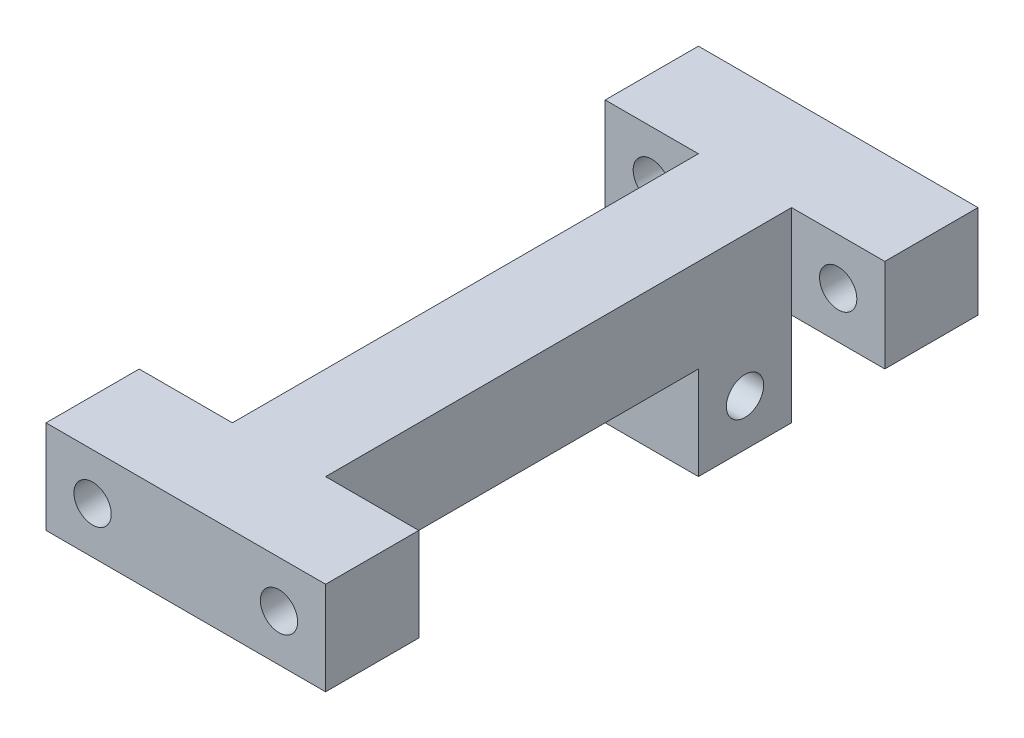
from build123d import *

# Parameters (mm, degrees)
SKETCH2_W           = 250
SKETCH2_H           = 100
BOSS_EXTRUDE1_DEPTH = 50
SKETCH3_W           = 150
SKETCH3_H           = 50
CUT_EXTRUDE1_DEPTH  = 109
SKETCH4_R           = 10
CUT_EXTRUDE2_DEPTH  = 109
SKETCH5_W           = 250
SKETCH5_H           = 50
BOSS_EXTRUDE2_DEPTH = 50
SKETCH8_W           = 150
SKETCH8_H           = 50
BOSS_EXTRUDE3_DEPTH = 50
SKETCH9_W           = 150
SKETCH9_H           = 50
BOSS_EXTRUDE4_DEPTH = 50
SKETCH10_W          = 50
SKETCH10_H          = 250
CUT_EXTRUDE5_DEPTH  = 50
SKETCH11_R          = 10
CUT_EXTRUDE6_DEPTH  = 398


with BuildPart() as part:
    # Sketch2 → Boss-Extrude1 (new body)
    with BuildSketch(Plane(origin=(0, 0, 0), x_dir=(0, 0, -1), z_dir=(1, 0, 0))):
        with Locations((125, 50)):
            Rectangle(SKETCH2_W, SKETCH2_H)
    extrude(amount=BOSS_EXTRUDE1_DEPTH)

    # Sketch3 → Cut-Extrude1 (cut)
    with BuildSketch(Plane(origin=(50, 0, 0), x_dir=(0, 0, -1), z_dir=(1, 0, 0))):
        with Locations((125, 25)):
            Rectangle(SKETCH3_W, SKETCH3_H)
    extrude(amount=-CUT_EXTRUDE1_DEPTH, mode=Mode.SUBTRACT)

    # Sketch4 → Cut-Extrude2 (cut)
    with BuildSketch(Plane(origin=(50, 0, 0), x_dir=(0, 0, -1), z_dir=(1, 0, 0))):
        with Locations((25, 25)):
            Circle(SKETCH4_R)
        with Locations((225, 25)):
            Circle(SKETCH4_R)
    extrude(amount=-CUT_EXTRUDE2_DEPTH, mode=Mode.SUBTRACT)

    # Sketch5 → Boss-Extrude2 (add)
    with BuildSketch(Plane(origin=(50, 0, 0), x_dir=(0, 0, -1), z_dir=(1, 0, 0))):
        with Locations((125, 75)):
            Rectangle(SKETCH5_W, SKETCH5_H)
    boss_extrude2 = extrude(amount=BOSS_EXTRUDE2_DEPTH)

    # Mirror1: Boss-Extrude2 across plane
    add(boss_extrude2.mirror(Plane(origin=(25, 0, 0), x_dir=(0, 0, 1), z_dir=(1, 0, 0))))

    # Sketch8 → Boss-Extrude3 (add)
    with BuildSketch(Plane.XY):
        with Locations((25, 75)):
            Rectangle(SKETCH8_W, SKETCH8_H)
    extrude(amount=BOSS_EXTRUDE3_DEPTH)

    # Sketch9 → Boss-Extrude4 (add)
    with BuildSketch(Plane(origin=(0, 0, -250), x_dir=(-1, 0, 0), z_dir=(0, 0, -1))):
        with Locations((-25, 75)):
            Rectangle(SKETCH9_W, SKETCH9_H)
    extrude(amount=BOSS_EXTRUDE4_DEPTH)

    # Sketch10 → Cut-Extrude5 (cut)
    with BuildSketch(Plane.XZ.offset(-50)):
        with Locations((75, -125)):
            Rectangle(SKETCH10_W, SKETCH10_H)
        with Locations((-25, -125)):
            Rectangle(SKETCH10_W, SKETCH10_H)
    extrude(amount=-CUT_EXTRUDE5_DEPTH, mode=Mode.SUBTRACT)

    # Sketch11 → Cut-Extrude6 (cut)
    with BuildSketch(Plane.XY.offset(50)):
        with Locations((-25, 75)):
            Circle(SKETCH11_R)
        with Locations((75, 75)):
            Circle(SKETCH11_R)
    extrude(amount=-CUT_EXTRUDE6_DEPTH, mode=Mode.SUBTRACT)


solid = part.part
